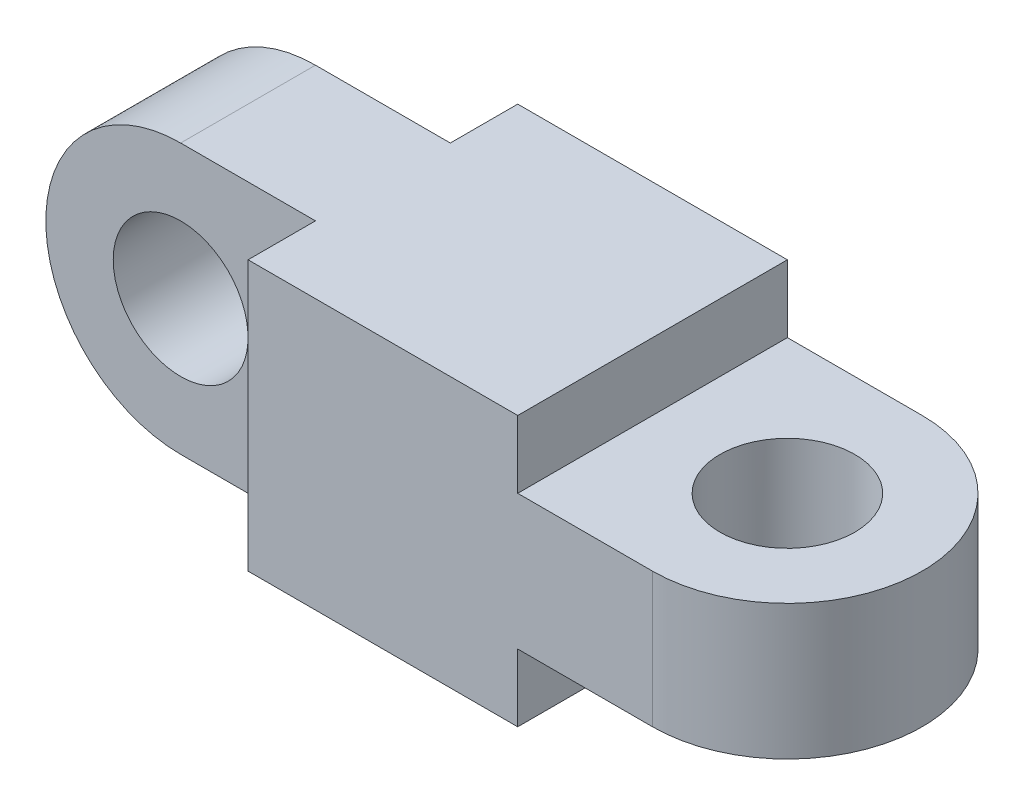
from build123d import *

# Parameters (mm, degrees)
ESQUISSE1_R        = 5
BOSS_EXTRU_1_DEPTH = 20
ESQUISSE2_R        = 5
BOSS_EXTRU_2_DEPTH = 20


with BuildPart() as part:
    # Esquisse1 → Boss.-Extru.1 (new body)
    with BuildSketch(Plane.XY):
        with BuildLine():
            Line((50, 5), (50, 15))
            Line((50, 15), (30, 15))
            Line((30, 15), (30, 20))
            Line((30, 20), (0, 20))
            ThreePointArc((0, 20), (-10, 10), (0, 0))
            Line((0, 0), (30, 0))
            Line((30, 0), (30, 5))
            Line((30, 5), (50, 5))
        make_face()
        with Locations((0, 10)):
            Circle(ESQUISSE1_R, mode=Mode.SUBTRACT)
    extrude(amount=BOSS_EXTRU_1_DEPTH)


with BuildPart() as body_2:
    # Esquisse2 → Boss.-Extru.2 (new body)
    with BuildSketch(Plane(origin=(0, 0, 0), x_dir=(1, 0, 0), z_dir=(0, 1, 0))):
        with BuildLine():
            Line((-10, -5), (-10, -15))
            Line((-10, -15), (10, -15))
            Line((10, -15), (10, -20))
            Line((10, -20), (40, -20))
            ThreePointArc((40, -20), (50, -10), (40, 0))
            Line((40, 0), (10, 0))
            Line((10, 0), (10, -5))
            Line((10, -5), (-10, -5))
        make_face()
        with Locations((40, -10)):
            Circle(ESQUISSE2_R, mode=Mode.SUBTRACT)
    extrude(amount=BOSS_EXTRU_2_DEPTH)

    # Combiner1: intersect part
    add(part.part, mode=Mode.INTERSECT)


solid = body_2.part
